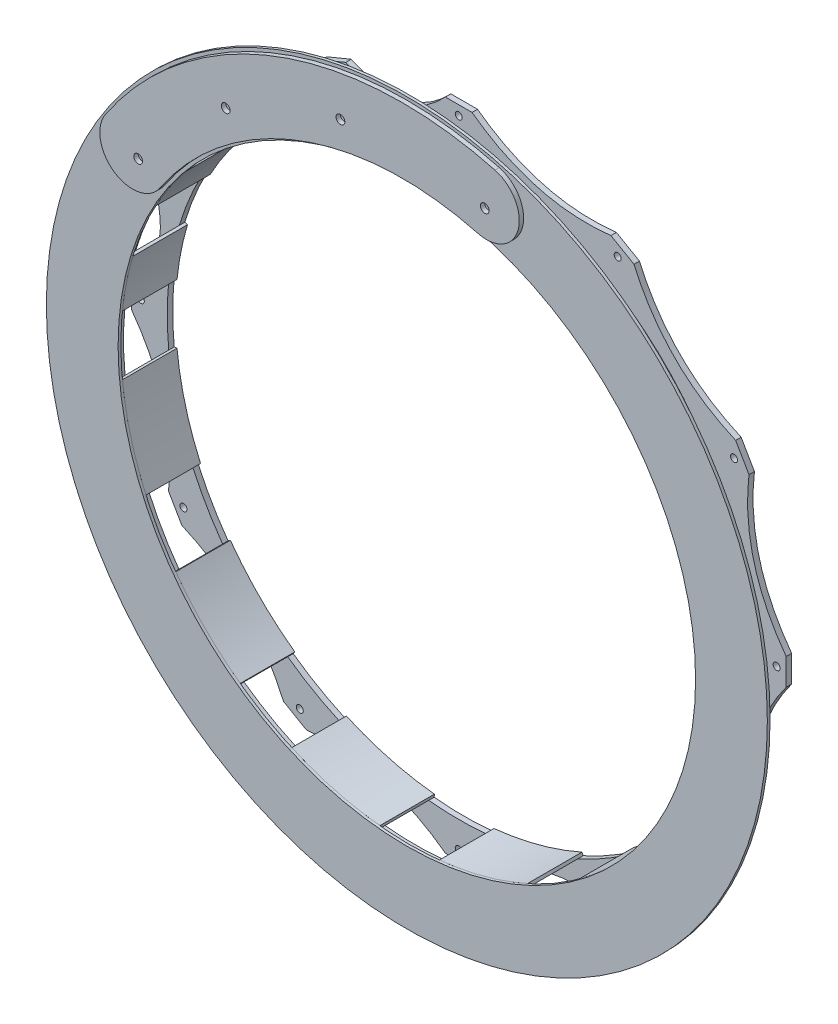
from build123d import *

# Parameters (mm, degrees)
SKETCH4_R           = 169.4688
SKETCH4_R_2         = 2.032
BOSS_EXTRUDE1_DEPTH = 3.175
SKETCH5_R           = 169.4688
SKETCH5_R_2         = 2.032
BOSS_EXTRUDE2_DEPTH = 3.175
BOSS_EXTRUDE3_DEPTH = 31.75
SKETCH7_R           = 209.55
SKETCH7_R_2         = 167.8432
BOSS_EXTRUDE4_DEPTH = 1.5875
SKETCH8_R           = 2.54
BOSS_EXTRUDE5_DEPTH = 2.54


with BuildPart() as part:
    # Sketch4 → Boss-Extrude1 (new body)
    with BuildSketch(Plane.XY):
        with BuildLine():
            Line((-7.735342369, 190.342886598), (7.735342369, 190.342886598))
            add(Edge.make_bspline(
                [(7.735342369, 190.342886598), (43.849986057, 163.650375876), (88.472440301, 168.709446408)],
                knots=[0, 0, 0, 1, 1, 1], degree=2))
            Line((88.472440301, 168.709446408), (101.870446297, 160.974104039))
            add(Edge.make_bspline(
                [(101.870446297, 160.974104039), (119.800389819, 119.800389819), (160.974104039, 101.870446297)],
                knots=[0, 0, 0, 1, 1, 1], degree=2))
            Line((160.974104039, 101.870446297), (168.709446408, 88.472440301))
            add(Edge.make_bspline(
                [(168.709446408, 88.472440301), (163.650375876, 43.849986057), (190.342886598, 7.735342369)],
                knots=[0, 0, 0, 1, 1, 1], degree=2))
            Line((190.342886598, 7.735342369), (190.342886598, -7.735342369))
            add(Edge.make_bspline(
                [(190.342886598, -7.735342369), (163.650375876, -43.849986057), (168.709446408, -88.472440301)],
                knots=[0, 0, 0, 1, 1, 1], degree=2))
            Line((168.709446408, -88.472440301), (160.974104039, -101.870446297))
            add(Edge.make_bspline(
                [(160.974104039, -101.870446297), (119.800389819, -119.800389819), (101.870446297, -160.974104039)],
                knots=[0, 0, 0, 1, 1, 1], degree=2))
            Line((101.870446297, -160.974104039), (88.472440301, -168.709446408))
            add(Edge.make_bspline(
                [(88.472440301, -168.709446408), (43.849986057, -163.650375876), (7.735342369, -190.342886598)],
                knots=[0, 0, 0, 1, 1, 1], degree=2))
            Line((7.735342369, -190.342886598), (-7.735342369, -190.342886598))
            add(Edge.make_bspline(
                [(-7.735342369, -190.342886598), (-43.849986057, -163.650375876), (-88.472440301, -168.709446408)],
                knots=[0, 0, 0, 1, 1, 1], degree=2))
            Line((-88.472440301, -168.709446408), (-101.870446297, -160.974104039))
            add(Edge.make_bspline(
                [(-101.870446297, -160.974104039), (-119.800389819, -119.800389819), (-160.974104039, -101.870446297)],
                knots=[0, 0, 0, 1, 1, 1], degree=2))
            Line((-160.974104039, -101.870446297), (-168.709446408, -88.472440301))
            add(Edge.make_bspline(
                [(-168.709446408, -88.472440301), (-163.650375876, -43.849986057), (-190.342886598, -7.735342369)],
                knots=[0, 0, 0, 1, 1, 1], degree=2))
            Line((-190.342886598, -7.735342369), (-190.342886598, 7.735342369))
            add(Edge.make_bspline(
                [(-190.342886598, 7.735342369), (-163.877360858, 32.597233808), (-178.814084455, 65.694544678)],
                knots=[0, 0, 0, 1, 1, 1], degree=2))
            Line((-178.814084455, 65.694544678), (-172.893709719, 79.987593661))
            add(Edge.make_bspline(
                [(-172.893709719, 79.987593661), (-138.92851822, 92.829068072), (-140.062458908, 129.12303282)],
                knots=[0, 0, 0, 1, 1, 1], degree=2))
            Line((-140.062458908, 129.12303282), (-129.12303282, 140.062458908))
            add(Edge.make_bspline(
                [(-129.12303282, 140.062458908), (-92.829068072, 138.92851822), (-79.987593661, 172.893709719)],
                knots=[0, 0, 0, 1, 1, 1], degree=2))
            Line((-79.987593661, 172.893709719), (-65.694544678, 178.814084455))
            add(Edge.make_bspline(
                [(-65.694544678, 178.814084455), (-32.597233808, 163.877360858), (-7.735342369, 190.342886598)],
                knots=[0, 0, 0, 1, 1, 1], degree=2))
        make_face()
        Circle(SKETCH4_R, mode=Mode.SUBTRACT)
        with Locations((0, 184.785)):
            Circle(SKETCH4_R_2, mode=Mode.SUBTRACT)
        with Locations((-160.028504238, -92.3925)):
            Circle(SKETCH4_R_2, mode=Mode.SUBTRACT)
        with Locations((-92.3925, -160.028504238)):
            Circle(SKETCH4_R_2, mode=Mode.SUBTRACT)
        with Locations((0, -184.785)):
            Circle(SKETCH4_R_2, mode=Mode.SUBTRACT)
        with Locations((92.3925, -160.028504238)):
            Circle(SKETCH4_R_2, mode=Mode.SUBTRACT)
        with Locations((160.028504238, -92.3925)):
            Circle(SKETCH4_R_2, mode=Mode.SUBTRACT)
        with Locations((184.785, 0)):
            Circle(SKETCH4_R_2, mode=Mode.SUBTRACT)
        with Locations((160.028504238, 92.3925)):
            Circle(SKETCH4_R_2, mode=Mode.SUBTRACT)
        with Locations((92.3925, 160.028504238)):
            Circle(SKETCH4_R_2, mode=Mode.SUBTRACT)
        with Locations((-70.71415805, 170.719079415)):
            Circle(SKETCH4_R_2, mode=Mode.SUBTRACT)
        with Locations((-130.662726562, 130.662726562)):
            Circle(SKETCH4_R_2, mode=Mode.SUBTRACT)
        with Locations((-170.719079415, 70.71415805)):
            Circle(SKETCH4_R_2, mode=Mode.SUBTRACT)
        with Locations((-184.785, 0)):
            Circle(SKETCH4_R_2, mode=Mode.SUBTRACT)
    extrude(amount=BOSS_EXTRUDE1_DEPTH)



with BuildPart() as body_2:
    # Sketch5 → Boss-Extrude2 (new body)
    with BuildSketch(Plane.XY.offset(28.575)):
        with BuildLine():
            Line((-129.12303282, 140.062458908), (-140.062458906, 129.123032763))
            add(Edge.make_bspline(
                [(-140.062458906, 129.123032763), (-138.928518246, 92.829068053), (-172.893709736, 79.987593655)],
                knots=[0, 0, 0, 1, 1, 1], degree=2))
            Line((-172.893709736, 79.987593655), (-178.814084432, 65.694544626))
            add(Edge.make_bspline(
                [(-178.814084432, 65.694544626), (-163.877360879, 32.597233789), (-190.342886598, 7.735342369)],
                knots=[0, 0, 0, 1, 1, 1], degree=2))
            Line((-190.342886598, 7.735342369), (-190.342886584, -7.735342387))
            add(Edge.make_bspline(
                [(-190.342886584, -7.735342387), (-163.650375877, -43.849986068), (-168.709446408, -88.472440301)],
                knots=[0, 0, 0, 1, 1, 1], degree=2))
            Line((-168.709446408, -88.472440301), (-160.974104018, -101.870446307))
            add(Edge.make_bspline(
                [(-160.974104018, -101.870446307), (-119.800389814, -119.800389829), (-101.870446297, -160.974104039)],
                knots=[0, 0, 0, 1, 1, 1], degree=2))
            Line((-101.870446297, -160.974104039), (-88.472440278, -168.709446405))
            add(Edge.make_bspline(
                [(-88.472440278, -168.709446405), (-43.849986048, -163.650375882), (-7.735342369, -190.342886598)],
                knots=[0, 0, 0, 1, 1, 1], degree=2))
            Line((-7.735342369, -190.342886598), (7.735342387, -190.342886584))
            add(Edge.make_bspline(
                [(7.735342387, -190.342886584), (43.849986068, -163.650375877), (88.472440301, -168.709446408)],
                knots=[0, 0, 0, 1, 1, 1], degree=2))
            Line((88.472440301, -168.709446408), (101.870446307, -160.974104018))
            add(Edge.make_bspline(
                [(101.870446307, -160.974104018), (119.800389829, -119.800389814), (160.974104039, -101.870446297)],
                knots=[0, 0, 0, 1, 1, 1], degree=2))
            Line((160.974104039, -101.870446297), (168.709446405, -88.472440278))
            add(Edge.make_bspline(
                [(168.709446405, -88.472440278), (163.650375882, -43.849986048), (190.342886598, -7.735342369)],
                knots=[0, 0, 0, 1, 1, 1], degree=2))
            Line((190.342886598, -7.735342369), (190.342886584, 7.735342387))
            add(Edge.make_bspline(
                [(190.342886584, 7.735342387), (163.650375877, 43.849986068), (168.709446408, 88.472440301)],
                knots=[0, 0, 0, 1, 1, 1], degree=2))
            Line((168.709446408, 88.472440301), (160.974104018, 101.870446307))
            add(Edge.make_bspline(
                [(160.974104018, 101.870446307), (119.800389814, 119.800389829), (101.870446297, 160.974104039)],
                knots=[0, 0, 0, 1, 1, 1], degree=2))
            Line((101.870446297, 160.974104039), (88.472440278, 168.709446405))
            add(Edge.make_bspline(
                [(88.472440278, 168.709446405), (43.849986048, 163.650375882), (7.735342369, 190.342886598)],
                knots=[0, 0, 0, 1, 1, 1], degree=2))
            Line((7.735342369, 190.342886598), (-7.735342408, 190.342886556))
            add(Edge.make_bspline(
                [(-7.735342408, 190.342886556), (-32.597233834, 163.87736087), (-65.694544678, 178.814084455)],
                knots=[0, 0, 0, 1, 1, 1], degree=2))
            Line((-65.694544678, 178.814084455), (-79.987593681, 172.893709665))
            add(Edge.make_bspline(
                [(-79.987593681, 172.893709665), (-92.829068101, 138.92851822), (-129.12303282, 140.062458908)],
                knots=[0, 0, 0, 1, 1, 1], degree=2))
        make_face()
        Circle(SKETCH5_R, mode=Mode.SUBTRACT)
        with Locations((0, 184.785)):
            Circle(SKETCH5_R_2, mode=Mode.SUBTRACT)
        with Locations((-160.028504238, -92.3925)):
            Circle(SKETCH5_R_2, mode=Mode.SUBTRACT)
        with Locations((-70.71415805, 170.719079415)):
            Circle(SKETCH5_R_2, mode=Mode.SUBTRACT)
        with Locations((92.3925, -160.028504238)):
            Circle(SKETCH5_R_2, mode=Mode.SUBTRACT)
        with Locations((0, -184.785)):
            Circle(SKETCH5_R_2, mode=Mode.SUBTRACT)
        with Locations((-92.3925, -160.028504238)):
            Circle(SKETCH5_R_2, mode=Mode.SUBTRACT)
        with Locations((184.785, 0)):
            Circle(SKETCH5_R_2, mode=Mode.SUBTRACT)
        with Locations((160.028504238, -92.3925)):
            Circle(SKETCH5_R_2, mode=Mode.SUBTRACT)
        with Locations((92.3925, 160.028504238)):
            Circle(SKETCH5_R_2, mode=Mode.SUBTRACT)
        with Locations((160.028504238, 92.3925)):
            Circle(SKETCH5_R_2, mode=Mode.SUBTRACT)
        with Locations((-184.785, 0)):
            Circle(SKETCH5_R_2, mode=Mode.SUBTRACT)
        with Locations((-170.719079415, 70.71415805)):
            Circle(SKETCH5_R_2, mode=Mode.SUBTRACT)
        with Locations((-130.662726562, 130.662726562)):
            Circle(SKETCH5_R_2, mode=Mode.SUBTRACT)
    extrude(amount=BOSS_EXTRUDE2_DEPTH)


with BuildPart() as part_1:
    add(part.part)

    add(body_2.part)  # Boss-Extrude3 merges body 2
    # Sketch6 → Boss-Extrude3 (add, through all)
    with BuildSketch(Plane.XY.offset(31.75)):
        with BuildLine():
            Line((17.471010309, 168.565826822), (17.30342268, 166.948888435))
            ThreePointArc((17.30342268, 166.948888435), (43.441016751, 162.124081647), (68.489240604, 153.233689859))
            Line((68.489240604, 153.233689859), (69.152574653, 154.717793392))
            ThreePointArc((69.152574653, 154.717793392), (43.861752991, 163.69429067), (17.471010309, 168.565826822))
        make_face()
        with BuildLine():
            Line((99.413252169, 137.246783083), (98.459647831, 135.930267178))
            ThreePointArc((98.459647831, 135.930267178), (118.683064896, 118.683064896), (135.930267178, 98.459647831))
            Line((135.930267178, 98.459647831), (137.246783083, 99.413252169))
            ThreePointArc((137.246783083, 99.413252169), (119.83253768, 119.83253768), (99.413252169, 137.246783083))
        make_face()
        with BuildLine():
            Line((154.717793392, 69.152574653), (153.233689859, 68.489240604))
            ThreePointArc((153.233689859, 68.489240604), (162.124081647, 43.441016751), (166.948888435, 17.30342268))
            Line((166.948888435, 17.30342268), (168.565826822, 17.471010309))
            ThreePointArc((168.565826822, 17.471010309), (163.69429067, 43.861752991), (154.717793392, 69.152574653))
        make_face()
        with BuildLine():
            Line((168.565826822, -17.471010309), (166.948888435, -17.30342268))
            ThreePointArc((166.948888435, -17.30342268), (162.124081647, -43.441016751), (153.233689859, -68.489240604))
            Line((153.233689859, -68.489240604), (154.717793392, -69.152574653))
            ThreePointArc((154.717793392, -69.152574653), (163.69429067, -43.861752991), (168.565826822, -17.471010309))
        make_face()
        with BuildLine():
            Line((137.246783083, -99.413252169), (135.930267178, -98.459647831))
            ThreePointArc((135.930267178, -98.459647831), (118.683064896, -118.683064896), (98.459647831, -135.930267178))
            Line((98.459647831, -135.930267178), (99.413252169, -137.246783083))
            ThreePointArc((99.413252169, -137.246783083), (119.83253768, -119.83253768), (137.246783083, -99.413252169))
        make_face()
        with BuildLine():
            Line((69.152574653, -154.717793392), (68.489240604, -153.233689859))
            ThreePointArc((68.489240604, -153.233689859), (43.441016751, -162.124081647), (17.30342268, -166.948888435))
            Line((17.30342268, -166.948888435), (17.471010309, -168.565826822))
            ThreePointArc((17.471010309, -168.565826822), (43.861752991, -163.69429067), (69.152574653, -154.717793392))
        make_face()
        with BuildLine():
            Line((-17.471010309, -168.565826822), (-17.30342268, -166.948888435))
            ThreePointArc((-17.30342268, -166.948888435), (-43.441016751, -162.124081647), (-68.489240604, -153.233689859))
            Line((-68.489240604, -153.233689859), (-69.152574653, -154.717793392))
            ThreePointArc((-69.152574653, -154.717793392), (-43.861752991, -163.69429067), (-17.471010309, -168.565826822))
        make_face()
        with BuildLine():
            Line((-99.413252169, -137.246783083), (-98.459647831, -135.930267178))
            ThreePointArc((-98.459647831, -135.930267178), (-118.683064896, -118.683064896), (-135.930267178, -98.459647831))
            Line((-135.930267178, -98.459647831), (-137.246783083, -99.413252169))
            ThreePointArc((-137.246783083, -99.413252169), (-119.83253768, -119.83253768), (-99.413252169, -137.246783083))
        make_face()
        with BuildLine():
            Line((-154.717793392, -69.152574653), (-153.233689859, -68.489240604))
            ThreePointArc((-153.233689859, -68.489240604), (-162.124081647, -43.441016751), (-166.948888435, -17.30342268))
            Line((-166.948888435, -17.30342268), (-168.565826822, -17.471010309))
            ThreePointArc((-168.565826822, -17.471010309), (-163.69429067, -43.861752991), (-154.717793392, -69.152574653))
        make_face()
        with BuildLine():
            Line((-47.902295599, 160.862394184), (-48.366240351, 162.420383474))
            ThreePointArc((-48.366240351, 162.420383474), (-33.061722764, 166.212504528), (-17.471010309, 168.565826822))
            Line((-17.471010309, 168.565826822), (-17.30342268, 166.948888435))
            ThreePointArc((-17.30342268, 166.948888435), (-32.744583936, 164.618139976), (-47.902295599, 160.862394184))
        make_face()
        with BuildLine():
            Line((-105.815323609, 130.286058639), (-106.840169358, 131.547909086))
            ThreePointArc((-106.840169358, 131.547909086), (-94.151820706, 140.908157433), (-80.648458025, 149.04865109))
            Line((-80.648458025, 149.04865109), (-79.874851713, 147.618927818))
            ThreePointArc((-79.874851713, 147.618927818), (-93.248685735, 139.556520432), (-105.815323609, 130.286058639))
        make_face()
        with BuildLine():
            Line((-147.618927818, 79.874851713), (-149.04865109, 80.648458025))
            ThreePointArc((-149.04865109, 80.648458025), (-140.908157433, 94.151820706), (-131.547909086, 106.840169358))
            Line((-131.547909086, 106.840169358), (-130.286058639, 105.815323609))
            ThreePointArc((-130.286058639, 105.815323609), (-139.556520432, 93.248685735), (-147.618927818, 79.874851713))
        make_face()
        with BuildLine():
            Line((-166.948888435, 17.30342268), (-168.565826822, 17.471010309))
            ThreePointArc((-168.565826822, 17.471010309), (-166.212504528, 33.061722764), (-162.420383474, 48.366240351))
            Line((-162.420383474, 48.366240351), (-160.862394184, 47.902295599))
            ThreePointArc((-160.862394184, 47.902295599), (-164.618139976, 32.744583936), (-166.948888435, 17.30342268))
        make_face()
    extrude(amount=-BOSS_EXTRUDE3_DEPTH)


with BuildPart() as body_2_2:
    # Sketch7 → Boss-Extrude4 (new body)
    with BuildSketch(Plane.XY.offset(31.75)):
        Circle(SKETCH7_R)
        Circle(SKETCH7_R_2, mode=Mode.SUBTRACT)
    extrude(amount=BOSS_EXTRUDE4_DEPTH)


with BuildPart() as body_3:
    # Sketch8 → Boss-Extrude5 (new body)
    with BuildSketch(Plane.XY.offset(33.3375)):
        with BuildLine():
            ThreePointArc((-141.036958841, 94.237883055), (-167.460067895, 88.98199988), (-172.71595107, 115.405108933))
            ThreePointArc((-172.71595107, 115.405108933), (-73.170686145, 194.409849573), (53.762851785, 200.645694421))
            ThreePointArc((53.762851785, 200.645694421), (67.233235967, 177.314304621), (43.901846167, 163.84392044))
            ThreePointArc((43.901846167, 163.84392044), (-59.74995932, 158.751833763), (-141.036958841, 94.237883055))
        make_face()
        with Locations((-102.742747798, 153.588489152)):
            Circle(SKETCH8_R, mode=Mode.SUBTRACT)
        with Locations((-36.049765154, 181.234408039)):
            Circle(SKETCH8_R, mode=Mode.SUBTRACT)
        with Locations((-153.643112309, 102.661045509)):
            Circle(SKETCH8_R, mode=Mode.SUBTRACT)
        with Locations((47.825877249, 178.488603811)):
            Circle(SKETCH8_R, mode=Mode.SUBTRACT)
    extrude(amount=BOSS_EXTRUDE5_DEPTH)


solid = Compound([part_1.part, body_2_2.part, body_3.part])
